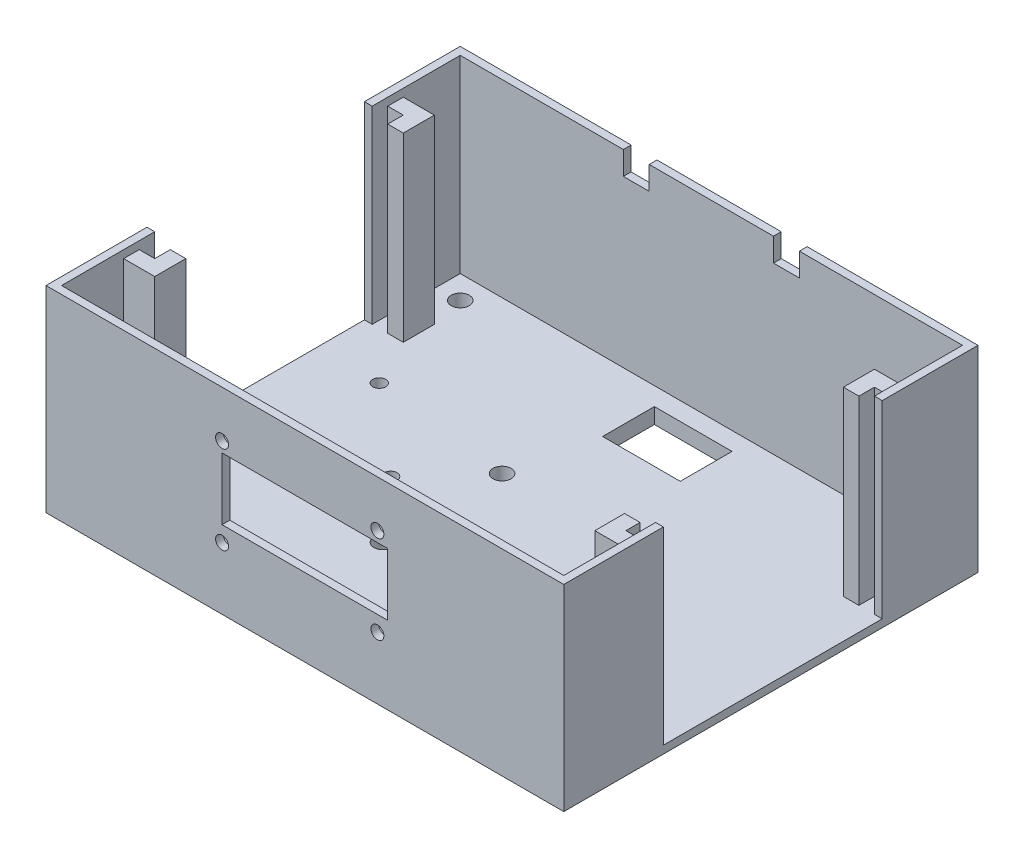
from build123d import *

# Parameters (mm, degrees)
ESQUISSE1_W             = 100
ESQUISSE1_H             = 80
ESQUISSE1_R             = 1.75
ESQUISSE1_R_2           = 1.25
ESQUISSE1_W_2           = 15
ESQUISSE1_H_2           = 10
BOSS_EXTRU_1_DEPTH      = 1.5
BOSS_EXTRU_2_DEPTH      = 36.5
ESQUISSE3_R             = 1.25
ESQUISSE3_W             = 32
ESQUISSE3_H             = 12
ENL_V_MAT_EXTRU_1_DEPTH = 5
ESQUISSE4_W             = 96
ESQUISSE4_H             = 76
ESQUISSE4_R             = 1.75
ESQUISSE4_R_2           = 1.25
ESQUISSE4_W_2           = 15
ESQUISSE4_H_2           = 10
BOSS_EXTRU_3_DEPTH      = 1.5
ENL_V_MAT_EXTRU_2_DEPTH = 1.5
ESQUISSE6_W             = 5
ESQUISSE6_H             = 4.5
ENL_V_MAT_EXTRU_3_DEPTH = 10


with BuildPart() as part:
    # Esquisse1 → Boss.-Extru.1 (new body)
    with BuildSketch(Plane(origin=(0, 0, 0), x_dir=(1, 0, 0), z_dir=(0, 1, 0))):
        with Locations((50, 40)):
            Rectangle(ESQUISSE1_W, ESQUISSE1_H)
        with Locations((6, 74)):
            Circle(ESQUISSE1_R, mode=Mode.SUBTRACT)
        with Locations((94, 74)):
            Circle(ESQUISSE1_R, mode=Mode.SUBTRACT)
        with Locations((94, 6)):
            Circle(ESQUISSE1_R, mode=Mode.SUBTRACT)
        with Locations((6, 6)):
            Circle(ESQUISSE1_R, mode=Mode.SUBTRACT)
        with Locations((88, 26.081709878)):
            Circle(ESQUISSE1_R, mode=Mode.SUBTRACT)
        with Locations((39, 26.081709878)):
            Circle(ESQUISSE1_R, mode=Mode.SUBTRACT)
        with Locations((39, 49.081709878)):
            Circle(ESQUISSE1_R, mode=Mode.SUBTRACT)
        with Locations((28.72, 37.850032574)):
            Circle(ESQUISSE1_R_2, mode=Mode.SUBTRACT)
        with Locations((12, 52.360032574)):
            Circle(ESQUISSE1_R_2, mode=Mode.SUBTRACT)
        with Locations((50, 70)):
            Rectangle(ESQUISSE1_W_2, ESQUISSE1_H_2, mode=Mode.SUBTRACT)
    extrude(amount=BOSS_EXTRU_1_DEPTH)

    # Esquisse2 → Boss.-Extru.2 (add)
    with BuildSketch(Plane(origin=(0, 1.5, 0), x_dir=(1, 0, 0), z_dir=(0, 1, 0))):
        Polygon((1.5, 78.5), (98.5, 78.5), (98.5, 67.5), (92.5, 67.5), (92.5, 64.5), (92.5, 61.5), (95.5, 61.5), (95.5, 64.5), (98.5, 64.5), (98.5, 61.5), (100, 61.5), (100, 80), (0, 80), (0, 61.5), (1.5, 61.5), (1.5, 64.5), (4.5, 64.5), (4.5, 61.5), (7.5, 61.5), (7.5, 64.5), (7.5, 67.5), (1.5, 67.5), align=None)
        Polygon((1.5, 1.5), (98.5, 1.5), (98.5, 13.5), (92.5, 13.5), (92.5, 16.5), (92.5, 19.237081293), (95.5, 19.237081293), (95.5, 16.5), (98.5, 16.5), (98.5, 19.237081293), (100, 19.237081293), (100, 0), (0, 0), (0, 19.5), (1.5, 19.5), (1.5, 16.5), (4.5, 16.5), (4.5, 19.5), (7.5, 19.5), (7.5, 16.5), (7.5, 13.5), (1.5, 13.5), align=None)
    extrude(amount=BOSS_EXTRU_2_DEPTH)

    # Esquisse3 → Enlèv. mat.-Extru.1 (cut)
    with BuildSketch(Plane.XY):
        with Locations((34, 29)):
            Circle(ESQUISSE3_R)
        with Locations((34, 12)):
            Circle(ESQUISSE3_R)
        with Locations((64, 12)):
            Circle(ESQUISSE3_R)
        with Locations((64, 29)):
            Circle(ESQUISSE3_R)
        with Locations((50, 21)):
            Rectangle(ESQUISSE3_W, ESQUISSE3_H)
    extrude(amount=-ENL_V_MAT_EXTRU_1_DEPTH, mode=Mode.SUBTRACT)

    # Esquisse4 → Boss.-Extru.3 (add)
    with BuildSketch(Plane.XZ):
        with Locations((50, -40)):
            Rectangle(ESQUISSE4_W, ESQUISSE4_H)
        with Locations((6, -6)):
            Circle(ESQUISSE4_R, mode=Mode.SUBTRACT)
        with Locations((6, -74)):
            Circle(ESQUISSE4_R, mode=Mode.SUBTRACT)
        with Locations((94, -74)):
            Circle(ESQUISSE4_R, mode=Mode.SUBTRACT)
        with Locations((94, -6)):
            Circle(ESQUISSE4_R, mode=Mode.SUBTRACT)
        with Locations((88, -26.081709878)):
            Circle(ESQUISSE4_R, mode=Mode.SUBTRACT)
        with Locations((39, -49.081709878)):
            Circle(ESQUISSE4_R, mode=Mode.SUBTRACT)
        with Locations((39, -26.081709878)):
            Circle(ESQUISSE4_R, mode=Mode.SUBTRACT)
        with Locations((28.72, -37.850032574)):
            Circle(ESQUISSE4_R_2, mode=Mode.SUBTRACT)
        with Locations((12, -52.360032574)):
            Circle(ESQUISSE4_R_2, mode=Mode.SUBTRACT)
        with Locations((50, -70)):
            Rectangle(ESQUISSE4_W_2, ESQUISSE4_H_2, mode=Mode.SUBTRACT)
    extrude(amount=BOSS_EXTRU_3_DEPTH)

    # Esquisse5 → Enlèv. mat.-Extru.2 (cut)
    with BuildSketch(Plane(origin=(0, 38, 0), x_dir=(1, 0, 0), z_dir=(0, 1, 0))):
        Polygon((1.5, 67.5), (7.5, 67.5), (7.5, 64.5), (7.5, 61.5), (4.5, 61.5), (4.5, 64.5), (1.5, 64.5), align=None)
        Polygon((1.5, 16.5), (4.5, 16.5), (4.5, 19.5), (7.5, 19.5), (7.5, 16.503082132), (7.5, 13.5), (1.5, 13.5), align=None)
        Polygon((92.5, 19.237081293), (95.5, 19.237081293), (95.5, 16.5), (98.5, 16.5), (98.5, 13.5), (92.5, 13.5), align=None)
        Polygon((95.5, 61.5), (92.5, 61.5), (92.5, 67.5), (95.5, 67.5), (98.5, 67.5), (98.5, 64.5), (95.5, 64.5), align=None)
    extrude(amount=-ENL_V_MAT_EXTRU_2_DEPTH, mode=Mode.SUBTRACT)

    # Esquisse6 → Enlèv. mat.-Extru.3 (cut)
    with BuildSketch(Plane.XY.offset(-78.5)):
        with Locations((35.5, 35.75)):
            Rectangle(ESQUISSE6_W, ESQUISSE6_H)
        with Locations((64.5, 35.75)):
            Rectangle(ESQUISSE6_W, ESQUISSE6_H)
    extrude(amount=-ENL_V_MAT_EXTRU_3_DEPTH, mode=Mode.SUBTRACT)


solid = part.part
